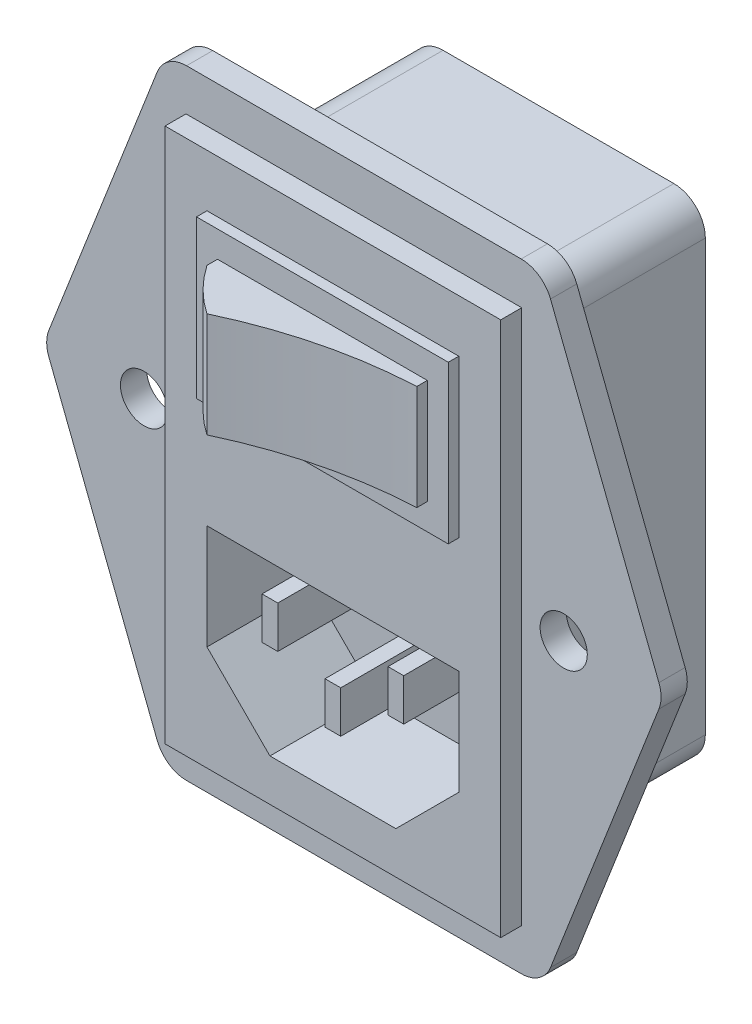
from build123d import *

# Parameters (mm, degrees)
SKETCH_1_W          = 28
SKETCH_1_H          = 47
EXTRUDE_1_DEPTH     = 17
EXTRUDE_2_DEPTH     = 2.5
SKETCH_3_W          = 32
SKETCH_3_H          = 51
EXTRUDE_3_DEPTH     = 2
SKETCH_5_W          = 1.5
SKETCH_5_H          = 4
CUT_EXTRUDE_3_DEPTH = 10
SKETCH_6_W          = 24
SKETCH_6_H          = 15
EXTRUDE_4_DEPTH     = 1
SKETCH_7_W          = 20
SKETCH_7_H          = 10
EXTRUDE_5_DEPTH     = 1
EXTRUDE_6_DEPTH     = 10
SKETCH_9_R          = 2.25
CUT_EXTRUDE_4_DEPTH = 20.5
FILLET_1_R          = 3


with BuildPart() as part:
    # Эскиз1 → Бобышка-Вытянуть1 (new body)
    with BuildSketch(Plane.XY):
        with Locations((14, 23.5)):
            Rectangle(SKETCH_1_W, SKETCH_1_H)
    extrude(amount=EXTRUDE_1_DEPTH)

    # Эскиз2 → Бобышка-Вытянуть2 (add)
    with BuildSketch(Plane.XY.offset(17)):
        Polygon((-4, 53), (32, 53), (43.5, 23.5), (32, -6), (-4, -6), (-15.5, 23.5), align=None)
    extrude(amount=EXTRUDE_2_DEPTH)

    # Эскиз3 → Бобышка-Вытянуть3 (add)
    with BuildSketch(Plane.XY.offset(19.5)):
        with Locations((14, 23.5)):
            Rectangle(SKETCH_3_W, SKETCH_3_H)
    extrude(amount=EXTRUDE_3_DEPTH)

    # Эскиз5 → Вырез-Вытянуть3 (cut)
    with BuildSketch(Plane.XY.offset(21.5)):
        Polygon((2, 18), (26, 18), (26, 8), (20, 2), (8, 2), (2, 8), align=None)
        with Locations((8, 13)):
            Rectangle(SKETCH_5_W, SKETCH_5_H, mode=Mode.SUBTRACT)
        with Locations((14, 9)):
            Rectangle(SKETCH_5_W, SKETCH_5_H, mode=Mode.SUBTRACT)
        with Locations((20, 13)):
            Rectangle(SKETCH_5_W, SKETCH_5_H, mode=Mode.SUBTRACT)
    extrude(amount=-CUT_EXTRUDE_3_DEPTH, mode=Mode.SUBTRACT)

    # Эскиз6 → Бобышка-Вытянуть4 (add)
    with BuildSketch(Plane.XY.offset(21.5)):
        with Locations((14, 36.5)):
            Rectangle(SKETCH_6_W, SKETCH_6_H)
    extrude(amount=EXTRUDE_4_DEPTH)

    # Эскиз7 → Бобышка-Вытянуть5 (add)
    with BuildSketch(Plane.XY.offset(22.5)):
        with Locations((14, 36.5)):
            Rectangle(SKETCH_7_W, SKETCH_7_H)
    extrude(amount=EXTRUDE_5_DEPTH)

    # Эскиз8 → Бобышка-Вытянуть6 (add)
    with BuildSketch(Plane.XZ.offset(-31.5)):
        with BuildLine():
            Line((4, 23.5), (24, 23.5))
            ThreePointArc((24, 23.5), (15.801732114, 24.706928456), (8, 27.5))
            ThreePointArc((8, 27.5), (5.80973161, 25.69026839), (4, 23.5))
        make_face()
    extrude(amount=-EXTRUDE_6_DEPTH)

    # Эскиз9 → Вырез-Вытянуть4 (cut, through all)
    with BuildSketch(Plane.XY.offset(19.5)):
        with Locations((-6, 23.5)):
            Circle(SKETCH_9_R)
        with Locations((34, 23.5)):
            Circle(SKETCH_9_R)
    extrude(amount=-CUT_EXTRUDE_4_DEPTH, mode=Mode.SUBTRACT)

    # Скругление1
    fillet_1_edges = [part.edges().sort_by_distance(p)[0] for p in [
        (43.5, 23.5, 18.25),
        (32, 53, 18.25),
        (-4, 53, 18.25),
        (-15.5, 23.5, 18.25),
        (-4, -6, 18.25),
        (32, -6, 18.25),
        (0, 47, 8.5),
        (28, 47, 8.5),
        (28, 0, 8.5),
        (0, 0, 8.5),
    ]]
    fillet(fillet_1_edges, radius=FILLET_1_R)


solid = part.part
